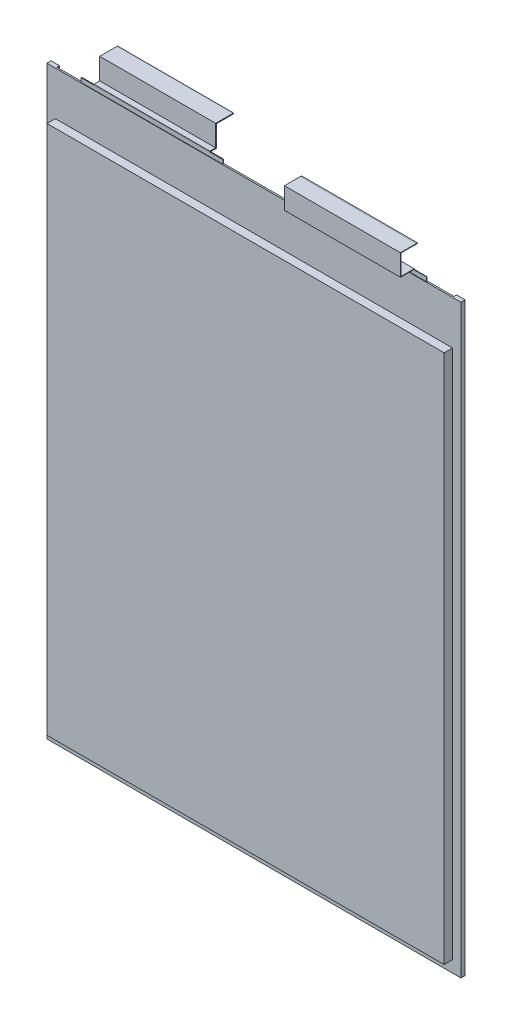
from build123d import *

# Parameters (mm, degrees)
SKETCH1_W                    = 160.6
SKETCH1_H                    = 227
INSULATION_DEPTH             = 0.3
INSULATION_DEPTH_BACK        = 0.3
SKETCH2_W                    = 154
SKETCH2_H                    = 205.5
MAIN_BODY_DEPTH              = 3.55
MAIN_BODY_DEPTH_BACK         = 3.55
SIDE_FOLDS_DEPTH             = 1.016
SKETCH6_W                    = 55
SKETCH6_H                    = 18.6
NEGATIVE_TAB_BASE_DEPTH      = 0.1
NEGATIVE_TAB_BASE_DEPTH_BACK = 0.1
SKETCH7_W                    = 55
SKETCH7_H                    = 18.6
POSITIVE_TAB_BASE_DEPTH      = 0.15
POSITIVE_TAB_BASE_DEPTH_BACK = 0.15
SKETCH113_W                  = 0.2
SKETCH113_H                  = 45
NEGATIVE_TAB_DEPTH           = 23.600222221
SKETCH113_ON_SEGMENT_2_W     = 0.2
SKETCH113_ON_SEGMENT_2_H     = 45
NEGATIVE_TAB_2_DEPTH         = 52.166374442
SKETCH113_ON_SEGMENT_3_W     = 0.2
SKETCH113_ON_SEGMENT_3_H     = 45
NEGATIVE_TAB_3_DEPTH         = 55.060444442
SKETCH113_ON_SEGMENT_4_W     = 0.2
SKETCH113_ON_SEGMENT_4_H     = 45
NEGATIVE_TAB_4_DEPTH         = 30.633497221
SKETCH113_ON_SEGMENT_5_W     = 0.2
SKETCH113_ON_SEGMENT_5_H     = 45
NEGATIVE_TAB_5_DEPTH         = 1.4
SKETCH110_W                  = 0.3
SKETCH110_H                  = 45
POSITIVE_TAB_DEPTH           = 23.650499994
SKETCH110_ON_SEGMENT_2_W     = 0.3
SKETCH110_ON_SEGMENT_2_H     = 45
POSITIVE_TAB_2_DEPTH         = 49.236449989
SKETCH110_ON_SEGMENT_3_W     = 0.3
SKETCH110_ON_SEGMENT_3_H     = 45
POSITIVE_TAB_3_DEPTH         = 55.260999989
SKETCH110_ON_SEGMENT_4_W     = 0.3
SKETCH110_ON_SEGMENT_4_H     = 45
POSITIVE_TAB_4_DEPTH         = 31.122574994
SKETCH110_ON_SEGMENT_5_W     = 0.3
SKETCH110_ON_SEGMENT_5_H     = 45
POSITIVE_TAB_5_DEPTH         = 1.15


with BuildPart() as part:
    # Sketch1 → Insulation (new, two sides)
    with BuildSketch(Plane.XY) as insulation_sk:
        Rectangle(SKETCH1_W, SKETCH1_H)
    extrude(amount=INSULATION_DEPTH)
    extrude(insulation_sk.sketch, amount=-INSULATION_DEPTH_BACK)

    # Sketch2 → Main Body (add, two sides)
    with BuildSketch(Plane.XY) as main_body_sk:
        with Locations((0, -6.25)):
            Rectangle(SKETCH2_W, SKETCH2_H)
    extrude(amount=MAIN_BODY_DEPTH)
    extrude(main_body_sk.sketch, amount=-MAIN_BODY_DEPTH_BACK)

    # Sketch5 → Side Folds (add)
    with BuildSketch(Plane(origin=(0, 0, -0.3), x_dir=(-1, 0, 0), z_dir=(0, 0, -1))):
        Polygon((-77, -109), (-77, 96.5), (-77, 113.5), (-80.3, 113.5), (-80.3, -113.5), (-77, -113.5), align=None)
        Polygon((77, 113.5), (77, 96.5), (77, -109), (77, -113.5), (80.3, -113.5), (80.3, 113.5), align=None)
    extrude(amount=SIDE_FOLDS_DEPTH)

    # Sketch6 → Negative Tab Base (add, two sides)
    with BuildSketch(Plane.XY) as negative_tab_base_sk:
        with Locations((39.3, 105.8)):
            Rectangle(SKETCH6_W, SKETCH6_H)
    extrude(amount=NEGATIVE_TAB_BASE_DEPTH)
    extrude(negative_tab_base_sk.sketch, amount=-NEGATIVE_TAB_BASE_DEPTH_BACK)

    # Sketch7 → Positive Tab Base (add, two sides)
    with BuildSketch(Plane.XY) as positive_tab_base_sk:
        with Locations((-39.7, 105.8)):
            Rectangle(SKETCH7_W, SKETCH7_H)
    extrude(amount=POSITIVE_TAB_BASE_DEPTH)
    extrude(positive_tab_base_sk.sketch, amount=-POSITIVE_TAB_BASE_DEPTH_BACK)


with BuildPart() as body_2:
    # Sketch113 → Negative Tab (new body)
    with BuildSketch(Plane(origin=(39.3, 115.1, 0), x_dir=(0, 0, -1), z_dir=(0, 1, 0))):
        Rectangle(SKETCH113_W, SKETCH113_H)
    extrude(amount=NEGATIVE_TAB_DEPTH)

    # Negative Tab mitre 1
    split(bisect_by=Plane(origin=(39.3, 115.2, 0), x_dir=(1, 0, 0), z_dir=(0, -0.707106781, -0.707106781)), keep=Keep.TOP)


with BuildPart() as body_3:
    # Sketch113 on segment 2 (carried to segment 2) → Negative Tab 2 (new body)
    with BuildSketch(Plane(origin=(39.3, 115.2, -23.500222221), x_dir=(0, 1, 0), z_dir=(0, 0, 1))):
        Rectangle(SKETCH113_ON_SEGMENT_2_W, SKETCH113_ON_SEGMENT_2_H)
    extrude(amount=NEGATIVE_TAB_2_DEPTH)

    # Negative Tab 2 mitre 1
    split(bisect_by=Plane(origin=(39.3, 115.2, 0), x_dir=(-1, 0, 0), z_dir=(0, 0.707106781, 0.707106781)), keep=Keep.TOP)

    # Negative Tab 2 mitre 2
    split(bisect_by=Plane(origin=(39.3, 115.2, 5.16593), x_dir=(1, 0, 0), z_dir=(0, -0.707106781, -0.707106781)), keep=Keep.TOP)


with BuildPart() as body_4:
    # Sketch113 on segment 3 (carried to segment 3) → Negative Tab 3 (new body)
    with BuildSketch(Plane(origin=(39.3, 91.699777779, 5.16593), x_dir=(0, 0, -1), z_dir=(0, 1, 0))):
        Rectangle(SKETCH113_ON_SEGMENT_3_W, SKETCH113_ON_SEGMENT_3_H)
    extrude(amount=NEGATIVE_TAB_3_DEPTH)

    # Negative Tab 3 mitre 1
    split(bisect_by=Plane(origin=(39.3, 115.2, 5.16593), x_dir=(-1, 0, 0), z_dir=(0, 0.707106781, 0.707106781)), keep=Keep.TOP)

    # Negative Tab 3 mitre 2
    split(bisect_by=Plane(origin=(39.3, 123.26, 5.16593), x_dir=(1, 0, 0), z_dir=(0, -0.707106781, 0.707106781)), keep=Keep.TOP)


with BuildPart() as body_5:
    # Sketch113 on segment 4 (carried to segment 4) → Negative Tab 4 (new body)
    with BuildSketch(Plane(origin=(39.3, 123.26, 28.666152221), x_dir=(0, -1, 0), z_dir=(0, 0, -1))):
        Rectangle(SKETCH113_ON_SEGMENT_4_W, SKETCH113_ON_SEGMENT_4_H)
    extrude(amount=NEGATIVE_TAB_4_DEPTH)

    # Negative Tab 4 mitre 1
    split(bisect_by=Plane(origin=(39.3, 123.26, 5.16593), x_dir=(-1, 0, 0), z_dir=(0, 0.707106781, -0.707106781)), keep=Keep.TOP)

    # Negative Tab 4 mitre 2
    split(bisect_by=Plane(origin=(39.3, 123.26, -0.967345), x_dir=(0, -1, 0), z_dir=(0, 0, 1)), keep=Keep.TOP)


with BuildPart() as body_6:
    # Sketch113 on segment 5 (carried to segment 5) → Negative Tab 5 (new body)
    with BuildSketch(Plane(origin=(39.3, 123.26, 0.032655), x_dir=(0, -1, 0), z_dir=(0, 0, -1))):
        Rectangle(SKETCH113_ON_SEGMENT_5_W, SKETCH113_ON_SEGMENT_5_H)
    extrude(amount=NEGATIVE_TAB_5_DEPTH)

    # Negative Tab 5 mitre 1
    split(bisect_by=Plane(origin=(39.3, 123.26, -0.967345), x_dir=(0, 1, 0), z_dir=(0, 0, -1)), keep=Keep.TOP)


with BuildPart() as body_2_1:
    add(body_2.part)

    # Negative Tab as one body: union body 3, body 4, body 5, body 6
    add(body_3.part)
    add(body_4.part)
    add(body_5.part)
    add(body_6.part)


with BuildPart() as body_3_2:
    # Sketch110 → Positive Tab (new body)
    with BuildSketch(Plane(origin=(-39.7, 115.1, 0), x_dir=(0, 0, -1), z_dir=(0, 1, 0))):
        Rectangle(SKETCH110_W, SKETCH110_H)
    extrude(amount=POSITIVE_TAB_DEPTH)

    # Positive Tab mitre 1
    split(bisect_by=Plane(origin=(-39.7, 115.25, 0), x_dir=(1, 0, 0), z_dir=(0, -0.707106781, 0.707106781)), keep=Keep.TOP)


with BuildPart() as body_4_2:
    # Sketch110 on segment 2 (carried to segment 2) → Positive Tab 2 (new body)
    with BuildSketch(Plane(origin=(-39.7, 115.25, 23.500499994), x_dir=(0, -1, 0), z_dir=(0, 0, -1))):
        Rectangle(SKETCH110_ON_SEGMENT_2_W, SKETCH110_ON_SEGMENT_2_H)
    extrude(amount=POSITIVE_TAB_2_DEPTH)

    # Positive Tab 2 mitre 1
    split(bisect_by=Plane(origin=(-39.7, 115.25, 0), x_dir=(-1, 0, 0), z_dir=(0, 0.707106781, -0.707106781)), keep=Keep.TOP)

    # Positive Tab 2 mitre 2
    split(bisect_by=Plane(origin=(-39.7, 115.25, -2.23545), x_dir=(1, 0, 0), z_dir=(0, -0.707106781, 0.707106781)), keep=Keep.TOP)


with BuildPart() as body_5_2:
    # Sketch110 on segment 3 (carried to segment 3) → Positive Tab 3 (new body)
    with BuildSketch(Plane(origin=(-39.7, 91.749500006, -2.23545), x_dir=(0, 0, -1), z_dir=(0, 1, 0))):
        Rectangle(SKETCH110_ON_SEGMENT_3_W, SKETCH110_ON_SEGMENT_3_H)
    extrude(amount=POSITIVE_TAB_3_DEPTH)

    # Positive Tab 3 mitre 1
    split(bisect_by=Plane(origin=(-39.7, 115.25, -2.23545), x_dir=(-1, 0, 0), z_dir=(0, 0.707106781, -0.707106781)), keep=Keep.TOP)

    # Positive Tab 3 mitre 2
    split(bisect_by=Plane(origin=(-39.7, 123.51, -2.23545), x_dir=(1, 0, 0), z_dir=(0, -0.707106781, 0.707106781)), keep=Keep.TOP)


with BuildPart() as body_6_2:
    # Sketch110 on segment 4 (carried to segment 4) → Positive Tab 4 (new body)
    with BuildSketch(Plane(origin=(-39.7, 123.51, 21.265049994), x_dir=(0, -1, 0), z_dir=(0, 0, -1))):
        Rectangle(SKETCH110_ON_SEGMENT_4_W, SKETCH110_ON_SEGMENT_4_H)
    extrude(amount=POSITIVE_TAB_4_DEPTH)

    # Positive Tab 4 mitre 1
    split(bisect_by=Plane(origin=(-39.7, 123.51, -2.23545), x_dir=(-1, 0, 0), z_dir=(0, 0.707106781, -0.707106781)), keep=Keep.TOP)

    # Positive Tab 4 mitre 2
    split(bisect_by=Plane(origin=(-39.7, 123.51, -8.857525), x_dir=(0, -1, 0), z_dir=(0, 0, 1)), keep=Keep.TOP)


with BuildPart() as body_7:
    # Sketch110 on segment 5 (carried to segment 5) → Positive Tab 5 (new body)
    with BuildSketch(Plane(origin=(-39.7, 123.51, -7.857525), x_dir=(0, -1, 0), z_dir=(0, 0, -1))):
        Rectangle(SKETCH110_ON_SEGMENT_5_W, SKETCH110_ON_SEGMENT_5_H)
    extrude(amount=POSITIVE_TAB_5_DEPTH)

    # Positive Tab 5 mitre 1
    split(bisect_by=Plane(origin=(-39.7, 123.51, -8.857525), x_dir=(0, 1, 0), z_dir=(0, 0, -1)), keep=Keep.TOP)


solid = Compound([part.part, body_2_1.part, body_3_2.part, body_4_2.part, body_5_2.part, body_6_2.part, body_7.part])
